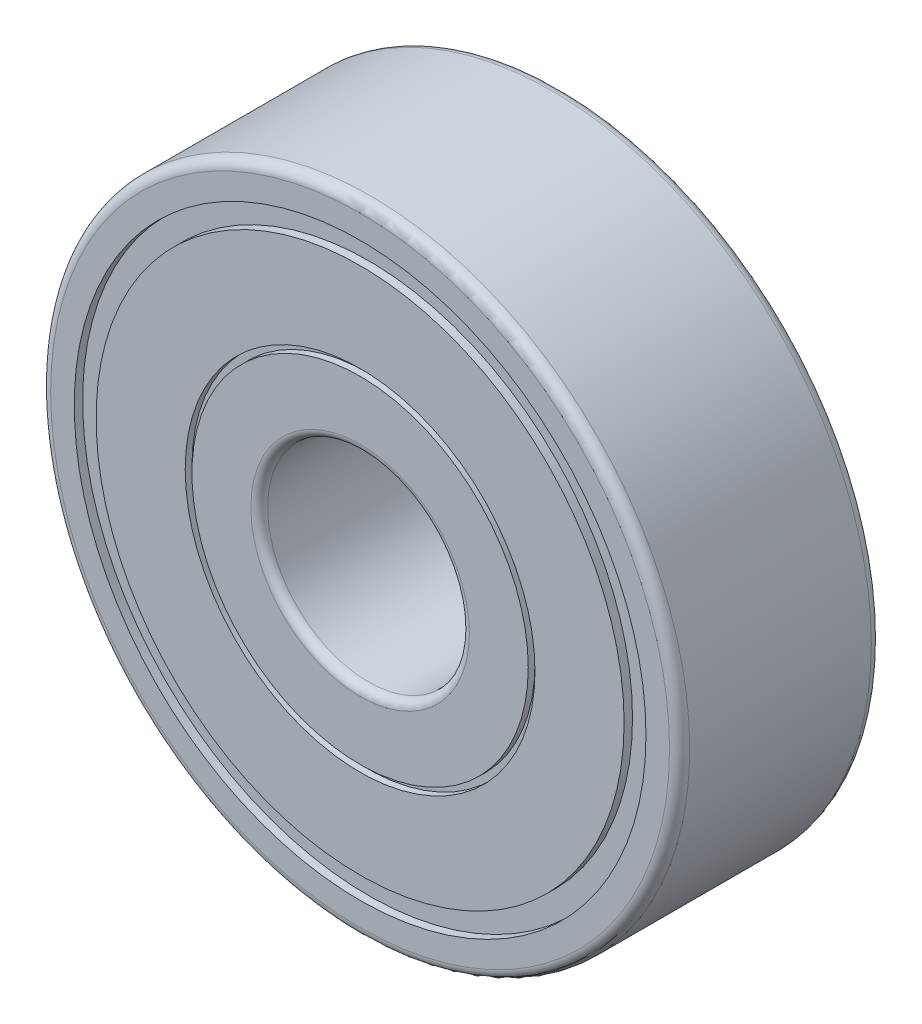
from build123d import *

# Parameters (mm, degrees)
SKETCH1_R           = 9.5
SKETCH1_R_2         = 3
BOSS_EXTRUDE1_DEPTH = 6
SKETCH2_R           = 5.2
SKETCH2_R_2         = 5
CUT_EXTRUDE1_DEPTH  = 0.2
SKETCH3_R           = 8.5
SKETCH3_R_2         = 7.85
CUT_EXTRUDE2_DEPTH  = 0.25
FILLET1_R           = 0.3
FILLET2_R           = 0.25


with BuildPart() as part:
    # Sketch1 → Boss-Extrude1 (new body)
    with BuildSketch(Plane.XY):
        Circle(SKETCH1_R)
        Circle(SKETCH1_R_2, mode=Mode.SUBTRACT)
    extrude(amount=BOSS_EXTRUDE1_DEPTH)

    # Sketch2 → Cut-Extrude1 (cut)
    with BuildSketch(Plane.XY.offset(6)):
        Circle(SKETCH2_R)
        Circle(SKETCH2_R_2, mode=Mode.SUBTRACT)
    cut_extrude1 = extrude(amount=-CUT_EXTRUDE1_DEPTH, mode=Mode.SUBTRACT)

    # Sketch3 → Cut-Extrude2 (cut)
    with BuildSketch(Plane.XY.offset(6)):
        Circle(SKETCH3_R)
        Circle(SKETCH3_R_2, mode=Mode.SUBTRACT)
    cut_extrude2 = extrude(amount=-CUT_EXTRUDE2_DEPTH, mode=Mode.SUBTRACT)

    # Mirror1: Cut-Extrude1, Cut-Extrude2 across plane
    add(cut_extrude1.mirror(Plane.XY.offset(3)), mode=Mode.SUBTRACT)
    add(cut_extrude2.mirror(Plane.XY.offset(3)), mode=Mode.SUBTRACT)

    # Fillet1
    fillet1_edges = [part.edges().sort_by_distance(p)[0] for p in [
        (-9.5, 0, 0),
        (-9.5, 0, 6),
    ]]
    fillet(fillet1_edges, radius=FILLET1_R)

    # Fillet2
    fillet2_edges = [part.edges().sort_by_distance(p)[0] for p in [
        (-3, 0, 0),
        (-3, 0, 6),
    ]]
    fillet(fillet2_edges, radius=FILLET2_R)


solid = part.part
